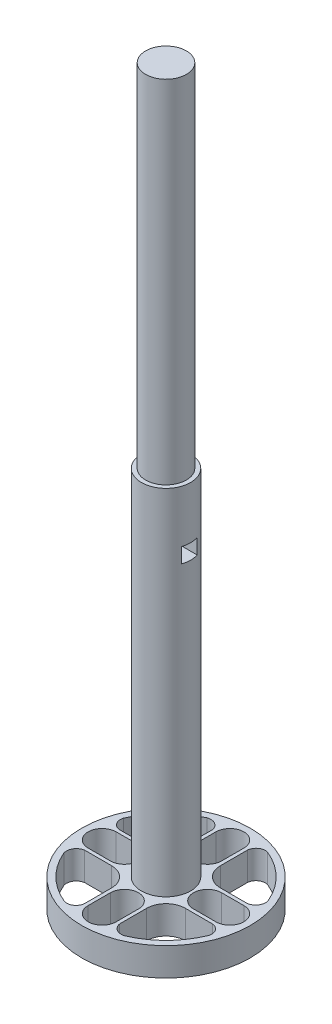
from build123d import *

# Parameters (mm, degrees)
SKETCH1_R               = 12
SKETCH1_R_2             = 3
BOSS_EXTRUDE1_DEPTH     = 4
SKETCH2_R               = 3.5
BOSS_EXTRUDE2_DEPTH     = 50.349572071
SKETCH3_W               = 2.224458382
SKETCH3_H               = 2.147670282
CUT_EXTRUDE1_DEPTH      = 4.436572991
CUT_EXTRUDE1_DEPTH_BACK = 100
SKETCH10_R              = 2.9
BOSS_EXTRUDE3_DEPTH     = 50


with BuildPart() as part:
    # Sketch1 → Boss-Extrude1 (new body)
    with BuildSketch(Plane(origin=(0, 0, 0), x_dir=(1, 0, 0), z_dir=(0, 1, 0))):
        Circle(SKETCH1_R)
        Circle(SKETCH1_R_2, mode=Mode.SUBTRACT)
        with BuildLine():
            Line((-2, -9.086626064), (-2, -5.913373936))
            ThreePointArc((-2, -5.913373936), (0, -3.913373936), (2, -5.913373936))
            Line((2, -5.913373936), (2, -9.086626064))
            ThreePointArc((2, -9.086626064), (0, -11.086626064), (-2, -9.086626064))
        make_face(mode=Mode.SUBTRACT)
        with BuildLine():
            Line((-9.086626064, 2), (-5.913373936, 2))
            ThreePointArc((-5.913373936, 2), (-3.913373936, 0), (-5.913373936, -2))
            Line((-5.913373936, -2), (-9.086626064, -2))
            ThreePointArc((-9.086626064, -2), (-11.086626064, 0), (-9.086626064, 2))
        make_face(mode=Mode.SUBTRACT)
        with BuildLine():
            Line((2, 9.086626064), (2, 5.913373936))
            ThreePointArc((2, 5.913373936), (0, 3.913373936), (-2, 5.913373936))
            Line((-2, 5.913373936), (-2, 9.086626064))
            ThreePointArc((-2, 9.086626064), (0, 11.086626064), (2, 9.086626064))
        make_face(mode=Mode.SUBTRACT)
        with BuildLine():
            Line((9.086626064, -2), (5.913373936, -2))
            ThreePointArc((5.913373936, -2), (3.913373936, 0), (5.913373936, 2))
            Line((5.913373936, 2), (9.086626064, 2))
            ThreePointArc((9.086626064, 2), (11.086626064, 0), (9.086626064, -2))
        make_face(mode=Mode.SUBTRACT)
        with BuildLine():
            Line((-5.255365036, -2.5), (-7.5, -2.5))
            Line((-7.5, -2.5), (-9.086626064, -2.5))
            ThreePointArc((-9.086626064, -2.5), (-10.071409475, -3.167974724), (-10.197041871, -4.351277348))
            ThreePointArc((-10.197041871, -4.351277348), (-7.780260231, -7.89815347), (-4.197441442, -10.261323639))
            ThreePointArc((-4.197441442, -10.261323639), (-3.073674879, -10.089196803), (-2.5, -9.107679575))
            Line((-2.5, -9.107679575), (-2.5, -7.5))
            Line((-2.5, -7.5), (-2.5, -5.256429725))
            Line((-2.5, -5.256429725), (-2.5, -5.255365036))
            ThreePointArc((-2.5, -5.255365036), (-3.303104097, -3.303104097), (-5.255365036, -2.5))
        make_face(mode=Mode.SUBTRACT)
        with BuildLine():
            Line((2.5, -5.255365036), (2.5, -7.5))
            Line((2.5, -7.5), (2.5, -9.086626064))
            ThreePointArc((2.5, -9.086626064), (3.167974724, -10.071409475), (4.351277348, -10.197041871))
            ThreePointArc((4.351277348, -10.197041871), (7.89815347, -7.780260231), (10.261323639, -4.197441442))
            ThreePointArc((10.261323639, -4.197441442), (10.089196803, -3.073674879), (9.107679575, -2.5))
            Line((9.107679575, -2.5), (7.5, -2.5))
            Line((7.5, -2.5), (5.256429725, -2.5))
            Line((5.256429725, -2.5), (5.255365036, -2.5))
            ThreePointArc((5.255365036, -2.5), (3.303104097, -3.303104097), (2.5, -5.255365036))
        make_face(mode=Mode.SUBTRACT)
        with BuildLine():
            Line((-2.5, 5.255365036), (-2.5, 7.5))
            Line((-2.5, 7.5), (-2.5, 9.086626064))
            ThreePointArc((-2.5, 9.086626064), (-3.167974724, 10.071409475), (-4.351277348, 10.197041871))
            ThreePointArc((-4.351277348, 10.197041871), (-7.89815347, 7.780260231), (-10.261323639, 4.197441442))
            ThreePointArc((-10.261323639, 4.197441442), (-10.089196803, 3.073674879), (-9.107679575, 2.5))
            Line((-9.107679575, 2.5), (-7.5, 2.5))
            Line((-7.5, 2.5), (-5.256429725, 2.5))
            Line((-5.256429725, 2.5), (-5.255365036, 2.5))
            ThreePointArc((-5.255365036, 2.5), (-3.303104097, 3.303104097), (-2.5, 5.255365036))
        make_face(mode=Mode.SUBTRACT)
        with BuildLine():
            Line((5.255365036, 2.5), (7.5, 2.5))
            Line((7.5, 2.5), (9.086626064, 2.5))
            ThreePointArc((9.086626064, 2.5), (10.071409475, 3.167974724), (10.197041871, 4.351277348))
            ThreePointArc((10.197041871, 4.351277348), (7.780260231, 7.89815347), (4.197441442, 10.261323639))
            ThreePointArc((4.197441442, 10.261323639), (3.073674879, 10.089196803), (2.5, 9.107679575))
            Line((2.5, 9.107679575), (2.5, 7.5))
            Line((2.5, 7.5), (2.5, 5.256429725))
            Line((2.5, 5.256429725), (2.5, 5.255365036))
            ThreePointArc((2.5, 5.255365036), (3.303104097, 3.303104097), (5.255365036, 2.5))
        make_face(mode=Mode.SUBTRACT)
    extrude(amount=BOSS_EXTRUDE1_DEPTH)

    # Sketch2 → Boss-Extrude2 (add)
    with BuildSketch(Plane(origin=(0, 4, 0), x_dir=(1, 0, 0), z_dir=(0, 1, 0))):
        Circle(SKETCH2_R)
    extrude(amount=BOSS_EXTRUDE2_DEPTH)

    # Sketch3 → Cut-Extrude1 (cut, two sides)
    with BuildSketch(Plane(origin=(0, 0, 0), x_dir=(0, 0, -1), z_dir=(1, 0, 0))) as cut_extrude1_sk:
        with Locations((0, 45.849702495)):
            Rectangle(SKETCH3_W, SKETCH3_H)
    extrude(amount=CUT_EXTRUDE1_DEPTH, mode=Mode.SUBTRACT)
    extrude(cut_extrude1_sk.sketch, amount=-CUT_EXTRUDE1_DEPTH_BACK, mode=Mode.SUBTRACT)

    # Sketch10 → Boss-Extrude3 (add)
    with BuildSketch(Plane(origin=(0, 54.349572071, 0), x_dir=(1, 0, 0), z_dir=(0, 1, 0))):
        Circle(SKETCH10_R)
    extrude(amount=BOSS_EXTRUDE3_DEPTH)


solid = part.part
